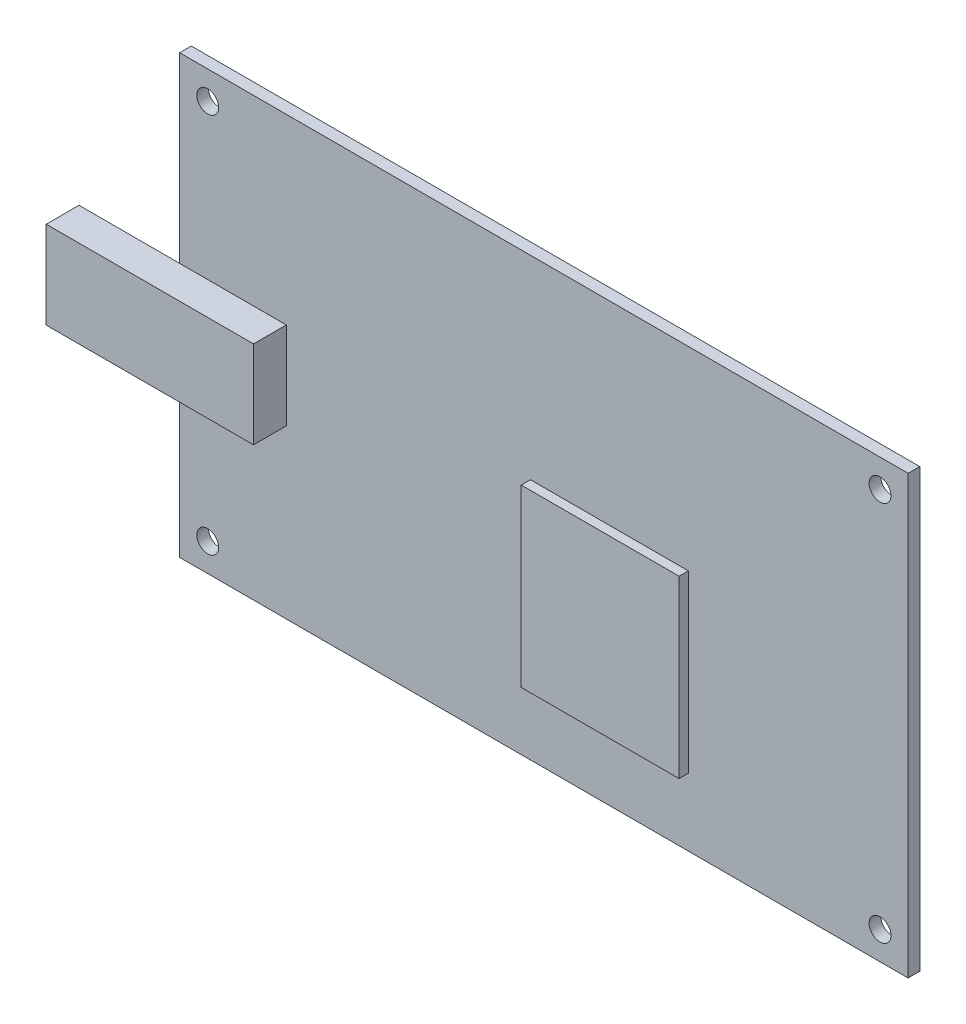
from build123d import *

# Parameters (mm, degrees)
SKETCH1_W                    = 100
SKETCH1_H                    = 60
BOSS_EXTRUDE1_DEPTH          = 1.6
SKETCH2_W                    = 28.451906957
SKETCH2_H                    = 12
BOSS_EXTRUDE2_DEPTH          = 4.5
SKETCH3_W                    = 21.668043294
SKETCH3_H                    = 24.059695689
BOSS_EXTRUDE3_DEPTH          = 1.27
F_3_0_3_DIAMETER_HOLE1_D     = 3
F_3_0_3_DIAMETER_HOLE1_DEPTH = 3.1496
F_3_0_3_DIAMETER_HOLE1_TIP   = 0.901290929


with BuildPart() as part:
    # Sketch1 → Boss-Extrude1 (new body)
    with BuildSketch(Plane.XY):
        Rectangle(SKETCH1_W, SKETCH1_H)
    extrude(amount=BOSS_EXTRUDE1_DEPTH)

    # Sketch2 → Boss-Extrude2 (add)
    with BuildSketch(Plane.XY.offset(1.6)):
        with Locations((-49.589851522, -1.044)):
            Rectangle(SKETCH2_W, SKETCH2_H)
    extrude(amount=BOSS_EXTRUDE2_DEPTH)

    # Sketch3 → Boss-Extrude3 (add)
    with BuildSketch(Plane.XY.offset(1.6)):
        with Locations((8.993071996, -8.71181328)):
            Rectangle(SKETCH3_W, SKETCH3_H)
    extrude(amount=BOSS_EXTRUDE3_DEPTH)

    # Ø3.0 (3) Diameter Hole1
    with Locations(Plane.XY.offset(1.6)):
        with Locations((-46.15, -26.15), (-46.15, 26.15), (46.15, -26.15), (46.15, 26.15)):
            Hole(F_3_0_3_DIAMETER_HOLE1_D / 2, depth=F_3_0_3_DIAMETER_HOLE1_DEPTH)
            with Locations((0, 0, -(F_3_0_3_DIAMETER_HOLE1_DEPTH + F_3_0_3_DIAMETER_HOLE1_TIP / 2))):  # 118° drill point
                Cone(0, F_3_0_3_DIAMETER_HOLE1_D / 2, F_3_0_3_DIAMETER_HOLE1_TIP, mode=Mode.SUBTRACT)


solid = part.part
